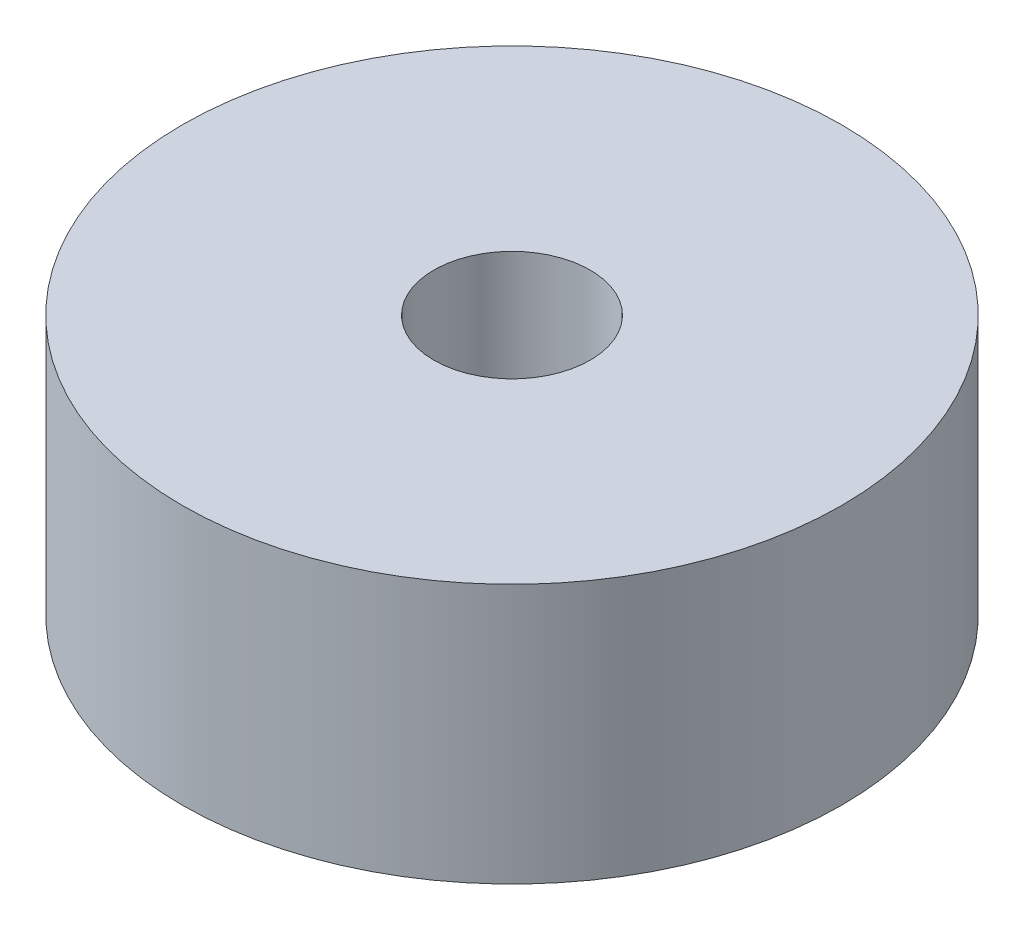
from build123d import *

# Parameters (mm, degrees)
SKETCH1_R           = 63.5
BOSS_EXTRUDE1_DEPTH = 50
SKETCH2_R           = 15.05
CUT_EXTRUDE1_DEPTH  = 50


with BuildPart() as part:
    # Sketch1 → Boss-Extrude1 (new body)
    with BuildSketch(Plane(origin=(0, 0, 0), x_dir=(1, 0, 0), z_dir=(0, 1, 0))):
        Circle(SKETCH1_R)
    extrude(amount=BOSS_EXTRUDE1_DEPTH)

    # Sketch2 → Cut-Extrude1 (cut)
    with BuildSketch(Plane(origin=(0, 50, 0), x_dir=(1, 0, 0), z_dir=(0, 1, 0))):
        Circle(SKETCH2_R)
    extrude(amount=-CUT_EXTRUDE1_DEPTH, mode=Mode.SUBTRACT)


solid = part.part
